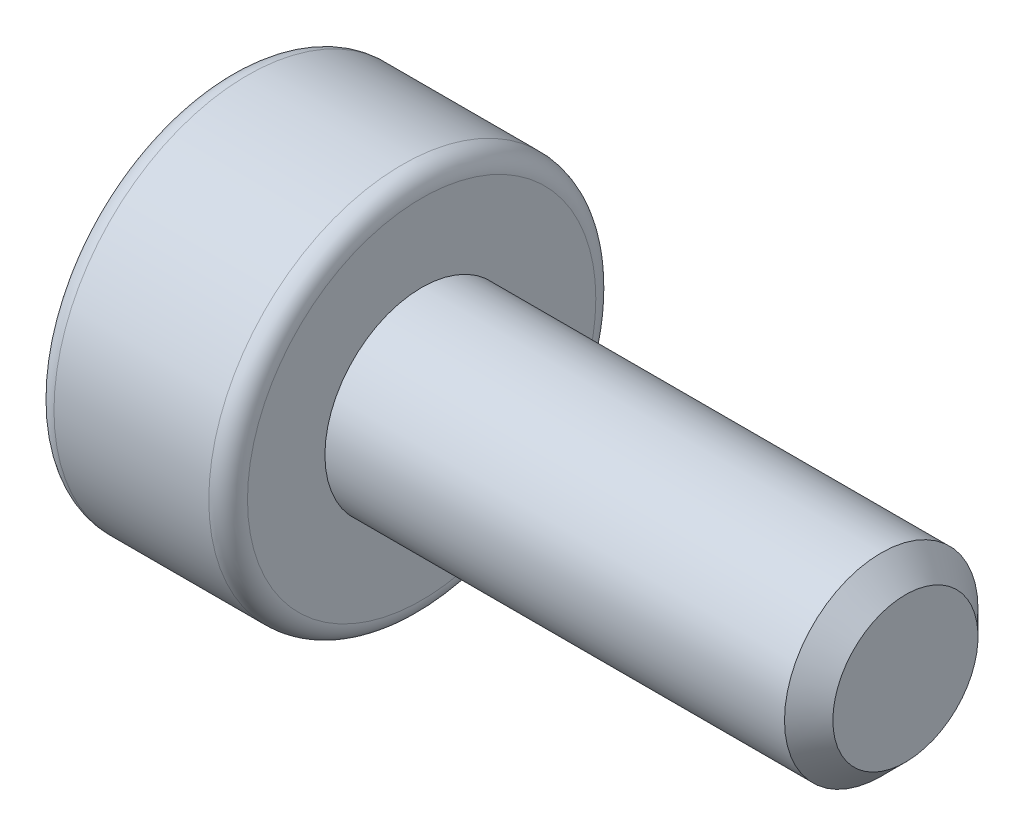
from build123d import *

# Parameters (mm, degrees)
CUT_EXTRUDE1_DEPTH = 0.8


with BuildPart() as part:
    # Sketch2 → Revolve1 (revolve)
    with BuildSketch(Plane.XY):
        with BuildLine():
            Line((0, 0), (0, 1.8))
            ThreePointArc((0, 1.8), (0.058578644, 1.941421356), (0.2, 2))
            Line((0.2, 2), (1.8, 2))
            ThreePointArc((1.8, 2), (1.941421356, 1.941421356), (2, 1.8))
            Line((2, 1.8), (2, 1))
            Line((2, 1), (6.75, 1))
            Line((6.75, 1), (7, 0.75))
            Line((7, 0.75), (7, 0))
            Line((7, 0), (0, 0))
        make_face()
    revolve(axis=Axis((-2.281841559, 0, 0), (1, 0, 0)))

    # Sketch3 → Cut-Extrude1 (cut)
    with BuildSketch(Plane.ZY):
        Polygon((0.433012702, -0.75), (0.866025404, 0), (0.433012702, 0.75), (-0.433012702, 0.75), (-0.866025404, 0), (-0.433012702, -0.75), align=None)
    extrude(amount=-CUT_EXTRUDE1_DEPTH, mode=Mode.SUBTRACT)


solid = part.part
